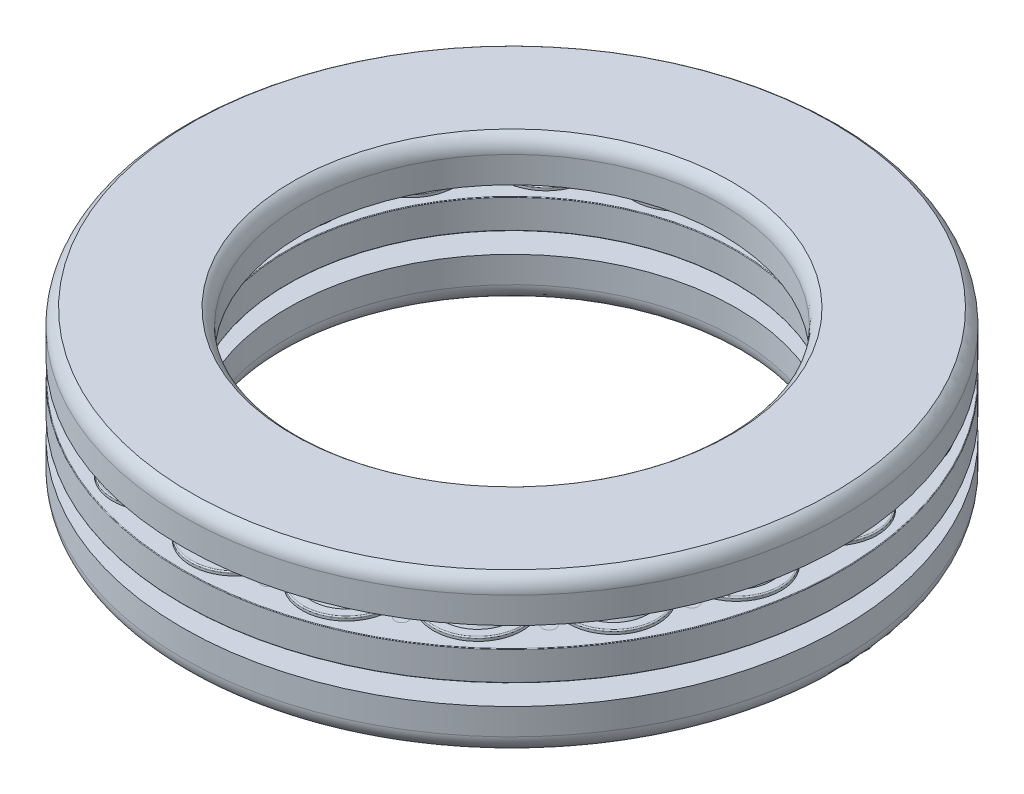
from build123d import *

# Parameters (mm, degrees)
CUT_EXTRUDE1_REACH             = 7.5
CUT_EXTRUDE1_DIRECTION_2_DEPTH = 6.5
SKETCH7_R                      = 0.46828125
CUT_EXTRUDE2_DEPTH             = 0.01
CIRPATTERN1_COUNT              = 18
CIRPATTERN2_COUNT              = 18


with BuildPart() as part:
    # Sketch3 → Revolve1 (revolve)
    with BuildSketch(Plane(origin=(0, 0, 0), x_dir=(0, 0, -1), z_dir=(1, 0, 0))):
        with BuildLine():
            Line((23.5, 2.5), (21.038470508, 2.5))
            ThreePointArc((21.038470508, 2.5), (19.75, 2.8125), (18.461529492, 2.5))
            Line((18.461529492, 2.5), (15, 2.5))
            Line((15, 2.5), (15, 4.375))
            ThreePointArc((15, 4.375), (15.169058766, 5.02038296), (15.6328125, 5.5))
            Line((15.6328125, 5.5), (22.8671875, 5.5))
            ThreePointArc((22.8671875, 5.5), (23.330941234, 5.02038296), (23.5, 4.375))
            Line((23.5, 4.375), (23.5, 2.5))
        make_face()
        with BuildLine():
            Line((18.461529492, -2.5), (16, -2.5))
            Line((16, -2.5), (16, -4.375))
            ThreePointArc((16, -4.375), (16.169058766, -5.02038296), (16.6328125, -5.5))
            Line((16.6328125, -5.5), (22.8671875, -5.5))
            ThreePointArc((22.8671875, -5.5), (23.330941234, -5.02038296), (23.5, -4.375))
            Line((23.5, -4.375), (23.5, -2.5))
            Line((23.5, -2.5), (21.038470508, -2.5))
            ThreePointArc((21.038470508, -2.5), (19.75, -2.8125), (18.461529492, -2.5))
        make_face()
        with BuildLine():
            Line((18.6953125, 1.0546875), (18.6953125, 1.233984375))
            ThreePointArc((18.6953125, 1.233984375), (18.720025365, 1.29364651), (18.7796875, 1.318359375))
            Line((18.7796875, 1.318359375), (20.7203125, 1.318359375))
            ThreePointArc((20.7203125, 1.318359375), (20.779974635, 1.29364651), (20.8046875, 1.233984375))
            Line((20.8046875, 1.233984375), (20.8046875, 1.0546875))
            Line((20.8046875, 1.0546875), (23.4578125, 1.0546875))
            ThreePointArc((23.4578125, 1.0546875), (23.487643567, 1.042331067), (23.5, 1.0125))
            Line((23.5, 1.0125), (23.5, -1.0125))
            ThreePointArc((23.5, -1.0125), (23.487643567, -1.042331067), (23.4578125, -1.0546875))
            Line((23.4578125, -1.0546875), (20.8046875, -1.0546875))
            Line((20.8046875, -1.0546875), (20.8046875, -1.233984375))
            ThreePointArc((20.8046875, -1.233984375), (20.779974635, -1.29364651), (20.7203125, -1.318359375))
            Line((20.7203125, -1.318359375), (18.7796875, -1.318359375))
            ThreePointArc((18.7796875, -1.318359375), (18.720025365, -1.29364651), (18.6953125, -1.233984375))
            Line((18.6953125, -1.233984375), (18.6953125, -1.0546875))
            Line((18.6953125, -1.0546875), (16.0421875, -1.0546875))
            ThreePointArc((16.0421875, -1.0546875), (16.012356433, -1.042331067), (16, -1.0125))
            Line((16, -1.0125), (16, 1.0125))
            ThreePointArc((16, 1.0125), (16.012356433, 1.042331067), (16.0421875, 1.0546875))
            Line((16.0421875, 1.0546875), (18.6953125, 1.0546875))
        make_face()
    revolve(axis=Axis((0, -5.5, 0), (0, 1, 0)))

    # Sketch4 → Revolve2 (revolve)
    with BuildSketch(Plane(origin=(0, 0, 0), x_dir=(0, 0, -1), z_dir=(1, 0, 0))):
        with BuildLine():
            Line((19.75, 1.318359375), (16.6703125, 1.318359375))
            ThreePointArc((16.6703125, 1.318359375), (16.610650365, 1.29364651), (16.5859375, 1.233984375))
            Line((16.5859375, 1.233984375), (16.5859375, 1.0546875))
            Line((16.5859375, 1.0546875), (19.75, 1.0546875))
            Line((19.75, 1.0546875), (19.75, 1.318359375))
        make_face()
        with BuildLine():
            Line((16.5859375, -1.233984375), (16.5859375, -1.0546875))
            Line((16.5859375, -1.0546875), (19.75, -1.0546875))
            Line((19.75, -1.0546875), (19.75, -1.318359375))
            Line((19.75, -1.318359375), (16.6703125, -1.318359375))
            ThreePointArc((16.6703125, -1.318359375), (16.610650365, -1.29364651), (16.5859375, -1.233984375))
        make_face()
    revolve(axis=Axis((0, 5.5, -19.75), (0, -1, 0)))

    # Sketch5 → Cut-Extrude1 (cut, up to next)
    with BuildSketch(Plane(origin=(0, 0, 0), x_dir=(1, 0, 0), z_dir=(0, 1, 0)), mode=Mode.PRIVATE) as cut_extrude1_sk1:
        with BuildLine():
            Line((4.590823697, 26.03585497), (0, 0))
            Line((0, 0), (-4.590823697, 26.03585497))
            ThreePointArc((-4.590823697, 26.03585497), (0, -26.4375), (4.590823697, 26.03585497))
        make_face()
    cut_extrude1_tool1 = extrude(cut_extrude1_sk1.sketch, amount=-CUT_EXTRUDE1_REACH, mode=Mode.PRIVATE) & part.part
    add(cut_extrude1_tool1.solids().sort_by_distance((0, 0, 1.031509))[0], mode=Mode.SUBTRACT)

    # Sketch5 → Cut-Extrude1 direction 2 (cut)
    with BuildSketch(Plane(origin=(0, 0, 0), x_dir=(1, 0, 0), z_dir=(0, 1, 0))):
        with BuildLine():
            Line((4.590823697, 26.03585497), (0, 0))
            Line((0, 0), (-4.590823697, 26.03585497))
            ThreePointArc((-4.590823697, 26.03585497), (0, -26.4375), (4.590823697, 26.03585497))
        make_face()
    extrude(amount=CUT_EXTRUDE1_DIRECTION_2_DEPTH, mode=Mode.SUBTRACT)


with BuildPart() as body_2:
    # Sketch6 → Revolve3 (revolve)
    with BuildSketch(Plane(origin=(0, 0, 0), x_dir=(0, 0, -1), z_dir=(1, 0, 0))):
        with BuildLine():
            Line((19.75, -2.8125), (19.75, 2.8125))
            ThreePointArc((19.75, 2.8125), (16.9375, 0), (19.75, -2.8125))
        make_face()
    revolve(axis=Axis((0, 5.5, -19.75), (0, -1, 0)))


with BuildPart() as part_1:
    add(part.part)

    # Combine1: cut body 2
    add(body_2.part, mode=Mode.SUBTRACT)

    # Sketch7 → Cut-Extrude2 (cut)
    with BuildSketch(Plane(origin=(0, 1.0546875, 0), x_dir=(1, 0, 0), z_dir=(0, 1, 0))):
        with Locations((-3.727161423, 21.137782816)):
            Circle(SKETCH7_R)
        with Locations((-3.050098869, 17.297970262)):
            Circle(SKETCH7_R)
        with Locations((3.050098869, 17.297970262)):
            Circle(SKETCH7_R)
        with Locations((3.727161423, 21.137782816)):
            Circle(SKETCH7_R)
    extrude(amount=-CUT_EXTRUDE2_DEPTH, mode=Mode.SUBTRACT)


with BuildPart() as cirpattern1_1:
    # CirPattern1: pattern copy
    add(part_1.part.rotate(Axis((0, 0, 0), (0, 1, 0)), 1 * 360 / CIRPATTERN1_COUNT))


with BuildPart() as cirpattern1_2:
    # CirPattern1: pattern copy
    add(part_1.part.rotate(Axis((0, 0, 0), (0, 1, 0)), 2 * 360 / CIRPATTERN1_COUNT))


with BuildPart() as cirpattern1_3:
    # CirPattern1: pattern copy
    add(part_1.part.rotate(Axis((0, 0, 0), (0, 1, 0)), 3 * 360 / CIRPATTERN1_COUNT))


with BuildPart() as cirpattern1_4:
    # CirPattern1: pattern copy
    add(part_1.part.rotate(Axis((0, 0, 0), (0, 1, 0)), 4 * 360 / CIRPATTERN1_COUNT))


with BuildPart() as cirpattern1_5:
    # CirPattern1: pattern copy
    add(part_1.part.rotate(Axis((0, 0, 0), (0, 1, 0)), 5 * 360 / CIRPATTERN1_COUNT))


with BuildPart() as cirpattern1_6:
    # CirPattern1: pattern copy
    add(part_1.part.rotate(Axis((0, 0, 0), (0, 1, 0)), 6 * 360 / CIRPATTERN1_COUNT))


with BuildPart() as cirpattern1_7:
    # CirPattern1: pattern copy
    add(part_1.part.rotate(Axis((0, 0, 0), (0, 1, 0)), 7 * 360 / CIRPATTERN1_COUNT))


with BuildPart() as cirpattern1_8:
    # CirPattern1: pattern copy
    add(part_1.part.rotate(Axis((0, 0, 0), (0, 1, 0)), 8 * 360 / CIRPATTERN1_COUNT))


with BuildPart() as cirpattern1_9:
    # CirPattern1: pattern copy
    add(part_1.part.rotate(Axis((0, 0, 0), (0, 1, 0)), 9 * 360 / CIRPATTERN1_COUNT))


with BuildPart() as cirpattern1_10:
    # CirPattern1: pattern copy
    add(part_1.part.rotate(Axis((0, 0, 0), (0, 1, 0)), 10 * 360 / CIRPATTERN1_COUNT))


with BuildPart() as cirpattern1_11:
    # CirPattern1: pattern copy
    add(part_1.part.rotate(Axis((0, 0, 0), (0, 1, 0)), 11 * 360 / CIRPATTERN1_COUNT))


with BuildPart() as cirpattern1_12:
    # CirPattern1: pattern copy
    add(part_1.part.rotate(Axis((0, 0, 0), (0, 1, 0)), 12 * 360 / CIRPATTERN1_COUNT))


with BuildPart() as cirpattern1_13:
    # CirPattern1: pattern copy
    add(part_1.part.rotate(Axis((0, 0, 0), (0, 1, 0)), 13 * 360 / CIRPATTERN1_COUNT))


with BuildPart() as cirpattern1_14:
    # CirPattern1: pattern copy
    add(part_1.part.rotate(Axis((0, 0, 0), (0, 1, 0)), 14 * 360 / CIRPATTERN1_COUNT))


with BuildPart() as cirpattern1_15:
    # CirPattern1: pattern copy
    add(part_1.part.rotate(Axis((0, 0, 0), (0, 1, 0)), 15 * 360 / CIRPATTERN1_COUNT))


with BuildPart() as cirpattern1_16:
    # CirPattern1: pattern copy
    add(part_1.part.rotate(Axis((0, 0, 0), (0, 1, 0)), 16 * 360 / CIRPATTERN1_COUNT))


with BuildPart() as cirpattern1_17:
    # CirPattern1: pattern copy
    add(part_1.part.rotate(Axis((0, 0, 0), (0, 1, 0)), 17 * 360 / CIRPATTERN1_COUNT))


with BuildPart() as part_2:
    add(part_1.part)

    add(cirpattern1_1.part)  # Revolve4 merges CirPattern1_1

    add(cirpattern1_2.part)  # Revolve4 merges CirPattern1_2

    add(cirpattern1_3.part)  # Revolve4 merges CirPattern1_3

    add(cirpattern1_4.part)  # Revolve4 merges CirPattern1_4

    add(cirpattern1_5.part)  # Revolve4 merges CirPattern1_5

    add(cirpattern1_6.part)  # Revolve4 merges CirPattern1_6

    add(cirpattern1_7.part)  # Revolve4 merges CirPattern1_7

    add(cirpattern1_8.part)  # Revolve4 merges CirPattern1_8

    add(cirpattern1_9.part)  # Revolve4 merges CirPattern1_9

    add(cirpattern1_10.part)  # Revolve4 merges CirPattern1_10

    add(cirpattern1_11.part)  # Revolve4 merges CirPattern1_11

    add(cirpattern1_12.part)  # Revolve4 merges CirPattern1_12

    add(cirpattern1_13.part)  # Revolve4 merges CirPattern1_13

    add(cirpattern1_14.part)  # Revolve4 merges CirPattern1_14

    add(cirpattern1_15.part)  # Revolve4 merges CirPattern1_15

    add(cirpattern1_16.part)  # Revolve4 merges CirPattern1_16

    add(cirpattern1_17.part)  # Revolve4 merges CirPattern1_17
    # Sketch8 → Revolve4 (revolve)
    with BuildSketch(Plane(origin=(0, 0, 0), x_dir=(0, 0, -1), z_dir=(1, 0, 0))):
        with BuildLine():
            Line((16.0421875, -1.0546875), (16.59246511, -1.0546875))
            Line((16.59246511, -1.0546875), (16.59246511, -0.50625))
            Line((16.59246511, -0.50625), (16, -0.50625))
            Line((16, -0.50625), (16, -1.0125))
            ThreePointArc((16, -1.0125), (16.012356433, -1.042331067), (16.0421875, -1.0546875))
        make_face()
    revolve(axis=Axis((0, -5.5, 0), (0, 1, 0)))


with BuildPart() as body_2_2:
    # Sketch6_2 → Revolve5 (revolve)
    with BuildSketch(Plane(origin=(0, 0, 0), x_dir=(0, 0, -1), z_dir=(1, 0, 0))):
        with BuildLine():
            Line((19.75, -2.8125), (19.75, 2.8125))
            ThreePointArc((19.75, 2.8125), (16.9375, 0), (19.75, -2.8125))
        make_face()
    revolve(axis=Axis((0, 5.5, -19.75), (0, -1, 0)))


with BuildPart() as cirpattern2_1:
    # CirPattern2: pattern copy
    add(body_2_2.part.rotate(Axis((0, 0, 0), (0, 1, 0)), 1 * 360 / CIRPATTERN2_COUNT))


with BuildPart() as cirpattern2_2:
    # CirPattern2: pattern copy
    add(body_2_2.part.rotate(Axis((0, 0, 0), (0, 1, 0)), 2 * 360 / CIRPATTERN2_COUNT))


with BuildPart() as cirpattern2_3:
    # CirPattern2: pattern copy
    add(body_2_2.part.rotate(Axis((0, 0, 0), (0, 1, 0)), 3 * 360 / CIRPATTERN2_COUNT))


with BuildPart() as cirpattern2_4:
    # CirPattern2: pattern copy
    add(body_2_2.part.rotate(Axis((0, 0, 0), (0, 1, 0)), 4 * 360 / CIRPATTERN2_COUNT))


with BuildPart() as cirpattern2_5:
    # CirPattern2: pattern copy
    add(body_2_2.part.rotate(Axis((0, 0, 0), (0, 1, 0)), 5 * 360 / CIRPATTERN2_COUNT))


with BuildPart() as cirpattern2_6:
    # CirPattern2: pattern copy
    add(body_2_2.part.rotate(Axis((0, 0, 0), (0, 1, 0)), 6 * 360 / CIRPATTERN2_COUNT))


with BuildPart() as cirpattern2_7:
    # CirPattern2: pattern copy
    add(body_2_2.part.rotate(Axis((0, 0, 0), (0, 1, 0)), 7 * 360 / CIRPATTERN2_COUNT))


with BuildPart() as cirpattern2_8:
    # CirPattern2: pattern copy
    add(body_2_2.part.rotate(Axis((0, 0, 0), (0, 1, 0)), 8 * 360 / CIRPATTERN2_COUNT))


with BuildPart() as cirpattern2_9:
    # CirPattern2: pattern copy
    add(body_2_2.part.rotate(Axis((0, 0, 0), (0, 1, 0)), 9 * 360 / CIRPATTERN2_COUNT))


with BuildPart() as cirpattern2_10:
    # CirPattern2: pattern copy
    add(body_2_2.part.rotate(Axis((0, 0, 0), (0, 1, 0)), 10 * 360 / CIRPATTERN2_COUNT))


with BuildPart() as cirpattern2_11:
    # CirPattern2: pattern copy
    add(body_2_2.part.rotate(Axis((0, 0, 0), (0, 1, 0)), 11 * 360 / CIRPATTERN2_COUNT))


with BuildPart() as cirpattern2_12:
    # CirPattern2: pattern copy
    add(body_2_2.part.rotate(Axis((0, 0, 0), (0, 1, 0)), 12 * 360 / CIRPATTERN2_COUNT))


with BuildPart() as cirpattern2_13:
    # CirPattern2: pattern copy
    add(body_2_2.part.rotate(Axis((0, 0, 0), (0, 1, 0)), 13 * 360 / CIRPATTERN2_COUNT))


with BuildPart() as cirpattern2_14:
    # CirPattern2: pattern copy
    add(body_2_2.part.rotate(Axis((0, 0, 0), (0, 1, 0)), 14 * 360 / CIRPATTERN2_COUNT))


with BuildPart() as cirpattern2_15:
    # CirPattern2: pattern copy
    add(body_2_2.part.rotate(Axis((0, 0, 0), (0, 1, 0)), 15 * 360 / CIRPATTERN2_COUNT))


with BuildPart() as cirpattern2_16:
    # CirPattern2: pattern copy
    add(body_2_2.part.rotate(Axis((0, 0, 0), (0, 1, 0)), 16 * 360 / CIRPATTERN2_COUNT))


with BuildPart() as cirpattern2_17:
    # CirPattern2: pattern copy
    add(body_2_2.part.rotate(Axis((0, 0, 0), (0, 1, 0)), 17 * 360 / CIRPATTERN2_COUNT))


solid = Compound([part_2.part, body_2_2.part, cirpattern2_1.part, cirpattern2_2.part, cirpattern2_3.part, cirpattern2_4.part, cirpattern2_5.part, cirpattern2_6.part, cirpattern2_7.part, cirpattern2_8.part, cirpattern2_9.part, cirpattern2_10.part, cirpattern2_11.part, cirpattern2_12.part, cirpattern2_13.part, cirpattern2_14.part, cirpattern2_15.part, cirpattern2_16.part, cirpattern2_17.part])
